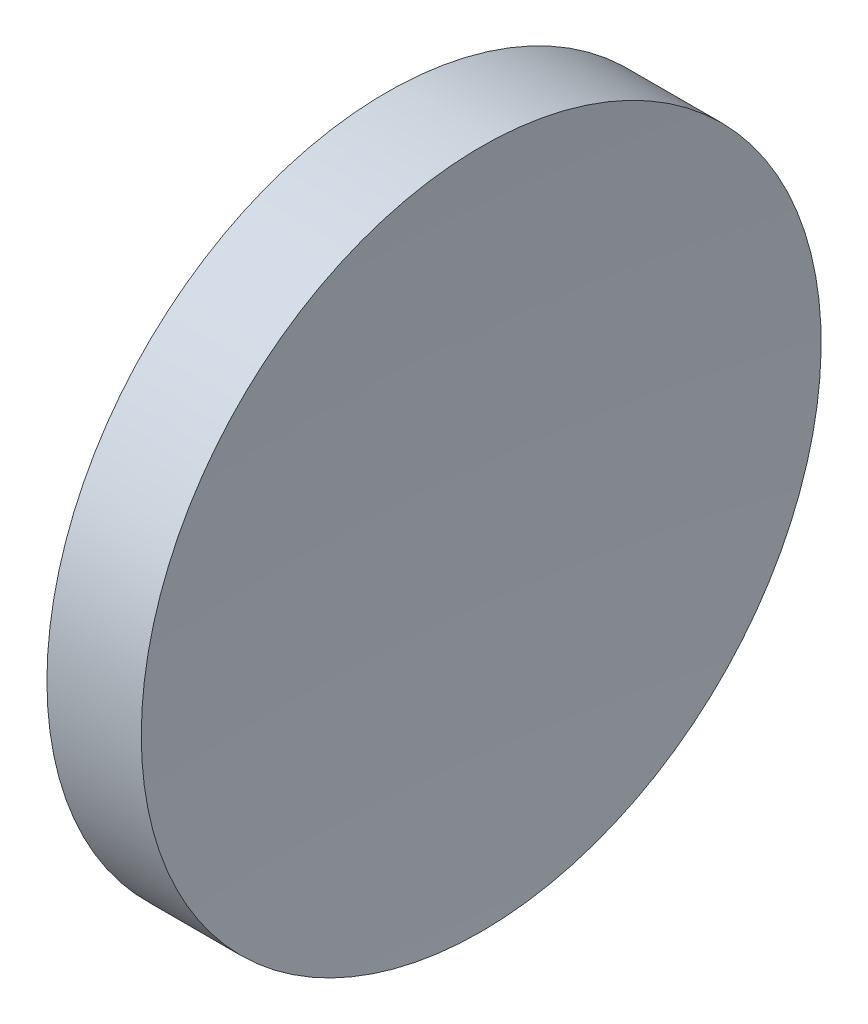
from build123d import *


with BuildPart() as part:
    # 草图1 → 旋转1 (revolve)
    with BuildSketch(Plane.XY, mode=Mode.PRIVATE) as revolve_1_sk:
        with BuildLine():
            Line((230.199611905, 138.756042247), (230.199611905, 176.256042247))
            Line((230.199611905, 176.256042247), (240.607845575, 176.256042247))
            ThreePointArc((240.607845575, 176.256042247), (239.551794767, 157.519258392), (239.199612455, 138.756042247))
            Line((239.199612455, 138.756042247), (230.199611905, 138.756042247))
        make_face()
    revolve(revolve_1_sk.sketch.rotate(Axis((217.970286004, 138.756042247, 0), (1, 0, 0)), 180), axis=Axis((217.970286004, 138.756042247, 0), (1, 0, 0)))  # turned: the seam where the file's is


solid = part.part
